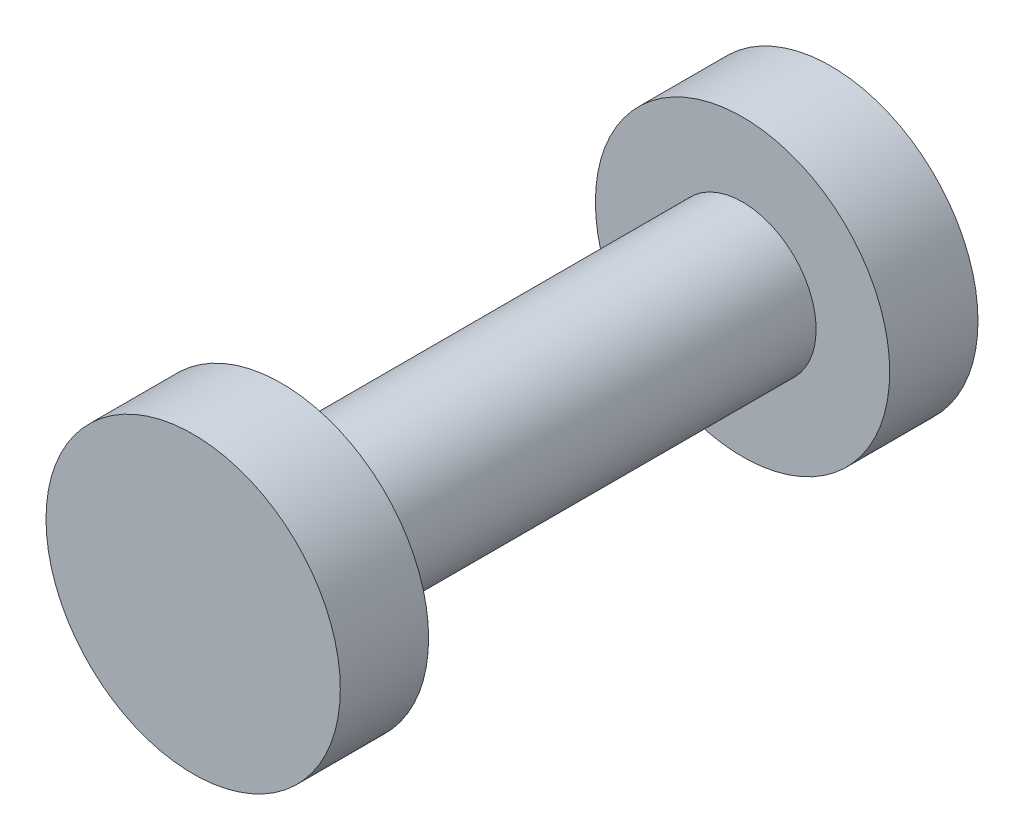
from build123d import *

# Parameters (mm, degrees)
SKETCH1_R           = 1.5
BOSS_EXTRUDE1_DEPTH = 6.5
SKETCH2_R           = 3
BOSS_EXTRUDE2_DEPTH = 1.8


with BuildPart() as part:
    # Sketch1 → Boss-Extrude1 (new body, symmetric)
    with BuildSketch(Plane.XY):
        Circle(SKETCH1_R)
    extrude(amount=BOSS_EXTRUDE1_DEPTH, both=True)

    # Sketch2 → Boss-Extrude2 (add)
    with BuildSketch(Plane.XY.offset(6.5)):
        Circle(SKETCH2_R)
    boss_extrude2 = extrude(amount=-BOSS_EXTRUDE2_DEPTH)

    # Mirror1: Boss-Extrude2 across plane
    add(boss_extrude2.mirror(Plane.XY))


solid = part.part
